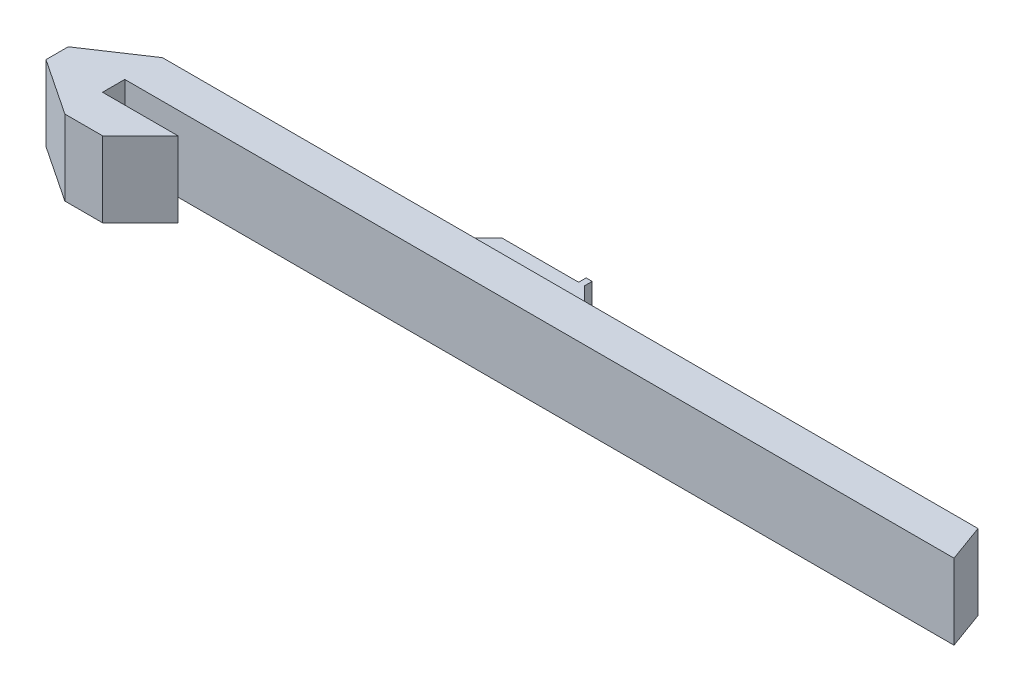
from build123d import *

# Parameters (mm, degrees)
SKIZZE1_W                       = 15
SKIZZE1_H                       = 5.9
AUFSATZ_LINEAR_AUSTRAGEN1_DEPTH = 20
SCHNITT_LINEAR_AUSTRAGEN1_DEPTH = 6.4
SCHNITT_LINEAR_AUSTRAGEN2_DEPTH = 6.4
SKIZZE4_W                       = 1.6
SKIZZE4_H                       = 7.2
AUFSATZ_LINEAR_AUSTRAGEN2_DEPTH = 2


with BuildPart() as part:
    # Skizze1 → Aufsatz-Linear austragen1 (new body)
    with BuildSketch(Plane(origin=(0, 0, 0), x_dir=(1, 0, 0), z_dir=(0, 1, 0))):
        Polygon((20, -5.9), (0, -5.9), (0, -15.9), (10, -15.9), align=None)
        Polygon((0, -5.9), (0, -15.9), (-15, -5.9), align=None)
        with Locations((-7.5, -2.95)):
            Rectangle(SKIZZE1_W, SKIZZE1_H)
        Polygon((0, 10), (0, 0), (-15, 0), align=None)
        Polygon((0, 10), (0, 0), (80, 0), (80, 10), (70, 10), align=None)
        Polygon((80, 10), (80, 0), (220, 0), (216.360297657, 10), (112, 10), align=None)
        Polygon((80, 20), (80, 10), (112, 10), (102, 20), align=None)
        Polygon((70, 10), (80, 10), (80, 20), align=None)
    extrude(amount=AUFSATZ_LINEAR_AUSTRAGEN1_DEPTH)

    # Skizze2 → Schnitt-Linear austragen1 (cut)
    with BuildSketch(Plane(origin=(0, 20, 0), x_dir=(1, 0, 0), z_dir=(0, 1, 0))):
        Polygon((70, 10), (112, 10), (102, 20), (80, 20), align=None)
    extrude(amount=-SCHNITT_LINEAR_AUSTRAGEN1_DEPTH, mode=Mode.SUBTRACT)

    # Skizze3 → Schnitt-Linear austragen2 (cut)
    with BuildSketch(Plane.XZ):
        Polygon((70, -10), (112, -10), (102, -20), (80, -20), align=None)
    extrude(amount=-SCHNITT_LINEAR_AUSTRAGEN2_DEPTH, mode=Mode.SUBTRACT)

    # Skizze4 → Aufsatz-Linear austragen2 (add)
    with BuildSketch(Plane(origin=(0, 0, -20), x_dir=(-1, 0, 0), z_dir=(0, 0, -1))):
        with Locations((-101.2, 10)):
            Rectangle(SKIZZE4_W, SKIZZE4_H)
    extrude(amount=AUFSATZ_LINEAR_AUSTRAGEN2_DEPTH)


solid = part.part
